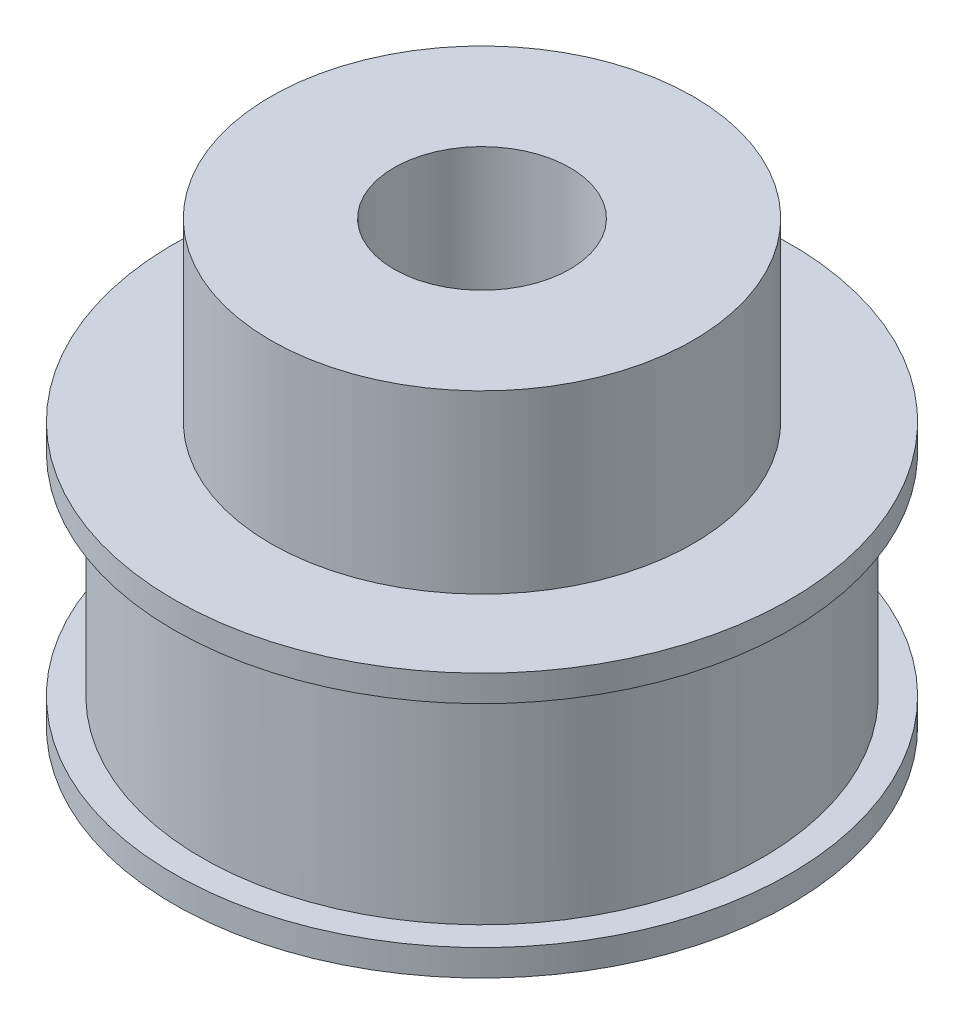
from build123d import *

# Parameters (mm, degrees)
SKETCH1_R           = 24.255
BOSS_EXTRUDE1_DEPTH = 15
SKETCH2_R           = 12
BOSS_EXTRUDE2_DEPTH = 10
SKETCH3_R           = 5
CUT_EXTRUDE1_DEPTH  = 26
SKETCH4_R           = 24.255
SKETCH4_R_2         = 15.915
CUT_EXTRUDE3_DEPTH  = 15
SKETCH5_R           = 17.5
SKETCH5_R_2         = 15.915
BOSS_EXTRUDE3_DEPTH = 1.5
SKETCH6_R           = 17.5
SKETCH6_R_2         = 15.915
BOSS_EXTRUDE4_DEPTH = 1.5
SCALE1_SCALE        = 1.5


with BuildPart() as part:
    # Sketch1 → Boss-Extrude1 (new body)
    with BuildSketch(Plane(origin=(0, 0, 0), x_dir=(1, 0, 0), z_dir=(0, 1, 0))):
        Circle(SKETCH1_R)
    extrude(amount=BOSS_EXTRUDE1_DEPTH)

    # Sketch2 → Boss-Extrude2 (add)
    with BuildSketch(Plane(origin=(0, 15, 0), x_dir=(1, 0, 0), z_dir=(0, 1, 0))):
        Circle(SKETCH2_R)
    extrude(amount=BOSS_EXTRUDE2_DEPTH)

    # Sketch3 → Cut-Extrude1 (cut)
    with BuildSketch(Plane(origin=(0, 25, 0), x_dir=(1, 0, 0), z_dir=(0, 1, 0))):
        Circle(SKETCH3_R)
    extrude(amount=-CUT_EXTRUDE1_DEPTH, mode=Mode.SUBTRACT)

    # Sketch4 → Cut-Extrude3 (cut)
    with BuildSketch(Plane.XZ):
        Circle(SKETCH4_R)
        Circle(SKETCH4_R_2, mode=Mode.SUBTRACT)
    extrude(amount=-CUT_EXTRUDE3_DEPTH, mode=Mode.SUBTRACT)

    # Sketch5 → Boss-Extrude3 (add)
    with BuildSketch(Plane.XZ):
        Circle(SKETCH5_R)
        Circle(SKETCH5_R_2, mode=Mode.SUBTRACT)
    extrude(amount=-BOSS_EXTRUDE3_DEPTH)

    # Sketch6 → Boss-Extrude4 (add)
    with BuildSketch(Plane(origin=(0, 15, 0), x_dir=(1, 0, 0), z_dir=(0, 1, 0))):
        Circle(SKETCH6_R)
        Circle(SKETCH6_R_2, mode=Mode.SUBTRACT)
    extrude(amount=-BOSS_EXTRUDE4_DEPTH)


with BuildPart() as part_1:
    # Scale1: scaled about (0, 10.616360153, 0)
    add(part.part.scale(SCALE1_SCALE).moved(Location((0, -5.308180077, 0))))


solid = part_1.part
